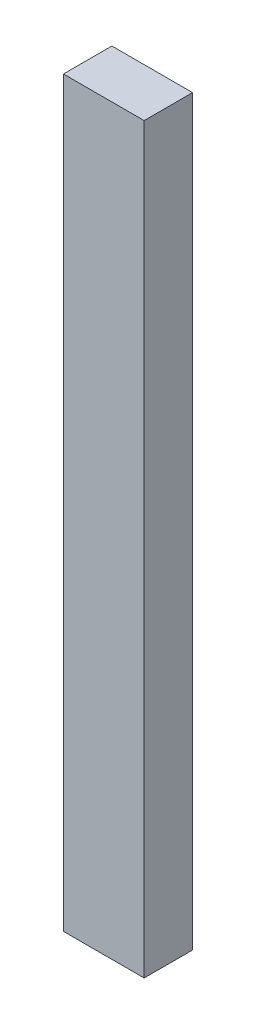
from build123d import *

# Parameters (mm, degrees)
SKETCH1_W           = 0.5
SKETCH1_H           = 0.3
BOSS_EXTRUDE1_DEPTH = 4.6


with BuildPart() as part:
    # Sketch1 → Boss-Extrude1 (new body)
    with BuildSketch(Plane(origin=(0, 0, 0), x_dir=(1, 0, 0), z_dir=(0, 1, 0))):
        Rectangle(SKETCH1_W, SKETCH1_H)
    extrude(amount=BOSS_EXTRUDE1_DEPTH)


solid = part.part
